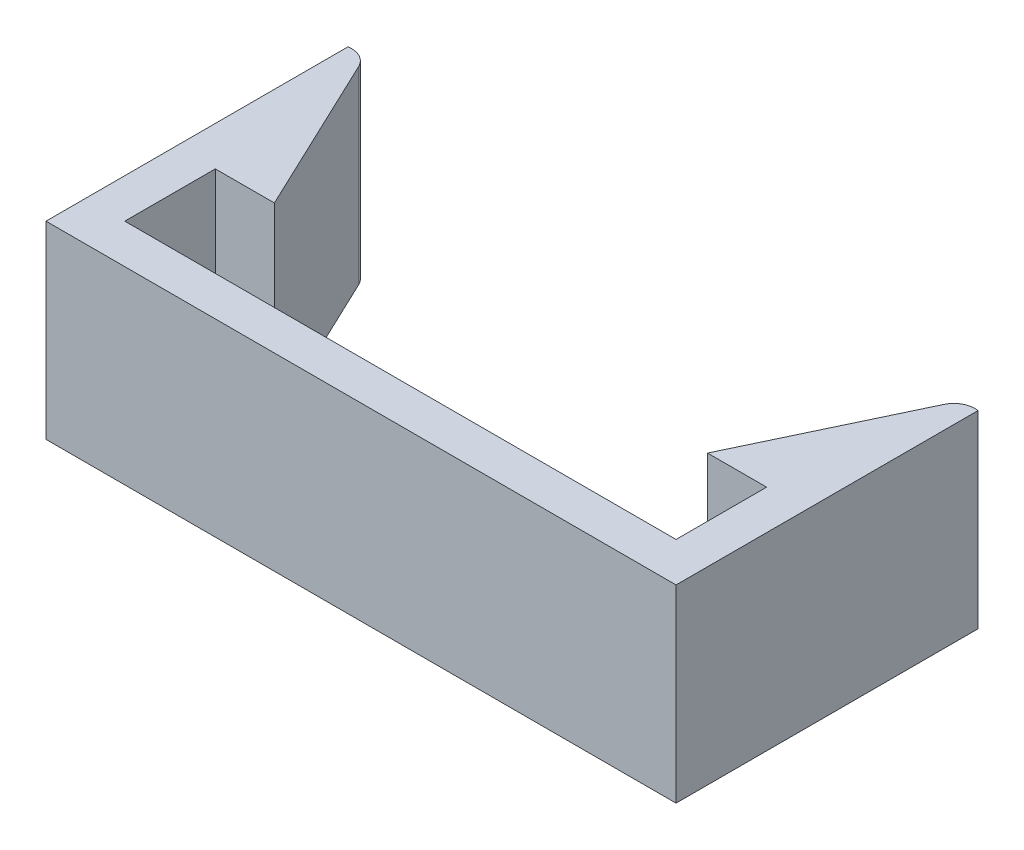
from build123d import *

# Parameters (mm, degrees)
EXTRUDE_1_DEPTH = 4.8


with BuildPart() as part:
    # 草圖1 → 填料-伸長1 (new body)
    with BuildSketch(Plane(origin=(0, 0, 0), x_dir=(1, 0, 0), z_dir=(0, 1, 0))):
        with BuildLine():
            Line((-7, 1), (7, 1))
            Line((7, 1), (7, 3.3))
            Line((7, 3.3), (5.5, 3.3))
            Line((5.5, 3.3), (7.431056476, 7.371095386))
            ThreePointArc((7.431056476, 7.371095386), (7.665760023, 7.614923881), (8, 7.668043813))
            Line((8, 7.668043813), (8, 1))
            Line((8, 1), (8, 0))
            Line((8, 0), (-8, 0))
            Line((-8, 0), (-8, 1))
            Line((-8, 1), (-8, 7.668043813))
            ThreePointArc((-8, 7.668043813), (-7.665760023, 7.614923881), (-7.431056476, 7.371095386))
            Line((-7.431056476, 7.371095386), (-5.5, 3.3))
            Line((-5.5, 3.3), (-7, 3.3))
            Line((-7, 3.3), (-7, 1))
        make_face()
    extrude(amount=EXTRUDE_1_DEPTH)


solid = part.part
